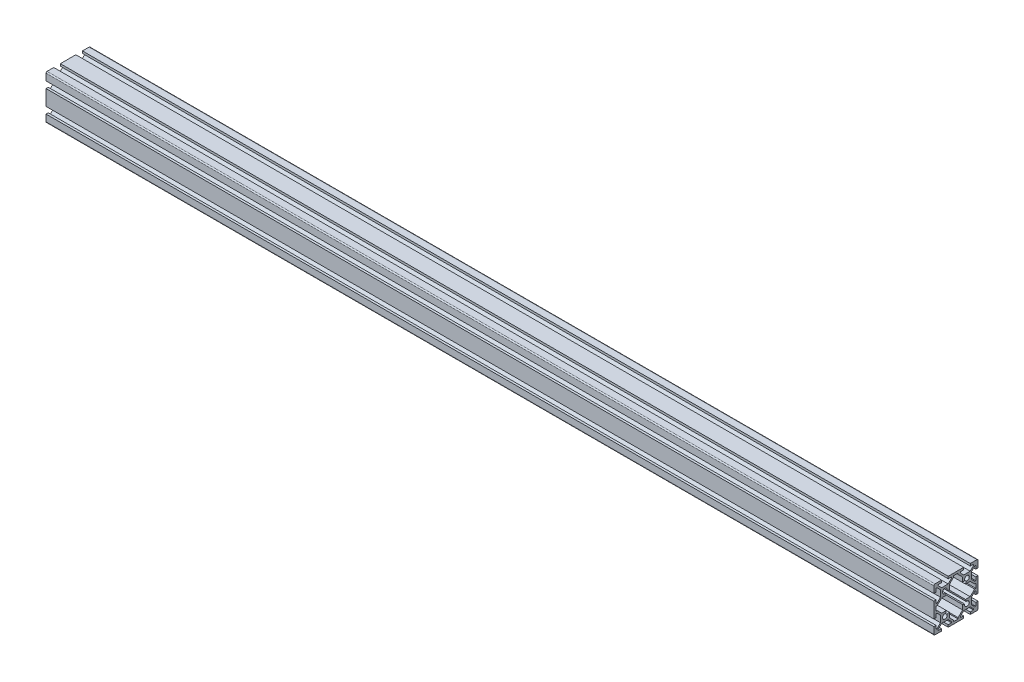
from build123d import *

# Parameters (mm, degrees)
BOSS_EXTRUDE1_DEPTH = 804


with BuildPart() as part:
    # Sketch1 → Boss-Extrude1 (new body)
    with BuildSketch(Plane(origin=(0, 0, 0), x_dir=(0, 0, -1), z_dir=(1, 0, 0))):
        with BuildLine():
            Line((-20, 19), (-20, 13))
            Line((-20, 13), (-18, 13))
            Line((-18, 13), (-18, 16))
            Line((-18, 16), (-17.060660172, 16))
            Line((-17.060660172, 16), (-14, 12.939339828))
            Line((-14, 12.939339828), (-14, 7.060660172))
            Line((-14, 7.060660172), (-17.060660172, 4))
            Line((-17.060660172, 4), (-18, 4))
            Line((-18, 4), (-18, 7))
            Line((-18, 7), (-20, 7))
            Line((-20, 7), (-20, -7))
            Line((-20, -7), (-18, -7))
            Line((-18, -7), (-18, -4))
            Line((-18, -4), (-17.060660172, -4))
            Line((-17.060660172, -4), (-14, -7.060660172))
            Line((-14, -7.060660172), (-14, -12.939339828))
            Line((-14, -12.939339828), (-17.060660172, -16))
            Line((-17.060660172, -16), (-18, -16))
            Line((-18, -16), (-18, -13))
            Line((-18, -13), (-20, -13))
            Line((-20, -13), (-20, -19))
            ThreePointArc((-20, -19), (-19.707106781, -19.707106781), (-19, -20))
            Line((-19, -20), (-13, -20))
            Line((-13, -20), (-13, -18))
            Line((-13, -18), (-16, -18))
            Line((-16, -18), (-16, -17.060660172))
            Line((-16, -17.060660172), (-12.939339828, -14))
            Line((-12.939339828, -14), (-7.060660172, -14))
            Line((-7.060660172, -14), (-4, -17.060660172))
            Line((-4, -17.060660172), (-4, -18))
            Line((-4, -18), (-7, -18))
            Line((-7, -18), (-7, -20))
            Line((-7, -20), (7, -20))
            Line((7, -20), (7, -18))
            Line((7, -18), (4, -18))
            Line((4, -18), (4, -17.060660172))
            Line((4, -17.060660172), (7.060660172, -14))
            Line((7.060660172, -14), (12.939339828, -14))
            Line((12.939339828, -14), (16, -17.060660172))
            Line((16, -17.060660172), (16, -18))
            Line((16, -18), (13, -18))
            Line((13, -18), (13, -20))
            Line((13, -20), (19, -20))
            ThreePointArc((19, -20), (19.707106781, -19.707106781), (20, -19))
            Line((20, -19), (20, -13))
            Line((20, -13), (18, -13))
            Line((18, -13), (18, -16))
            Line((18, -16), (17.060660172, -16))
            Line((17.060660172, -16), (14, -12.939339828))
            Line((14, -12.939339828), (14, -7.060660172))
            Line((14, -7.060660172), (17.060660172, -4))
            Line((17.060660172, -4), (18, -4))
            Line((18, -4), (18, -7))
            Line((18, -7), (20, -7))
            Line((20, -7), (20, 7))
            Line((20, 7), (18, 7))
            Line((18, 7), (18, 4))
            Line((18, 4), (17.060660172, 4))
            Line((17.060660172, 4), (14, 7.060660172))
            Line((14, 7.060660172), (14, 12.939339828))
            Line((14, 12.939339828), (17.060660172, 16))
            Line((17.060660172, 16), (18, 16))
            Line((18, 16), (18, 13))
            Line((18, 13), (20, 13))
            Line((20, 13), (20, 19))
            ThreePointArc((20, 19), (19.707106781, 19.707106781), (19, 20))
            Line((19, 20), (13, 20))
            Line((13, 20), (13, 18))
            Line((13, 18), (16, 18))
            Line((16, 18), (16, 17.060660172))
            Line((16, 17.060660172), (12.939339828, 14))
            Line((12.939339828, 14), (7.060660172, 14))
            Line((7.060660172, 14), (4, 17.060660172))
            Line((4, 17.060660172), (4, 18))
            Line((4, 18), (7, 18))
            Line((7, 18), (7, 20))
            Line((7, 20), (-7, 20))
            Line((-7, 20), (-7, 18))
            Line((-7, 18), (-4, 18))
            Line((-4, 18), (-4, 17.060660172))
            Line((-4, 17.060660172), (-7.060660172, 14))
            Line((-7.060660172, 14), (-12.939339828, 14))
            Line((-12.939339828, 14), (-16, 17.060660172))
            Line((-16, 17.060660172), (-16, 18))
            Line((-16, 18), (-13, 18))
            Line((-13, 18), (-13, 20))
            Line((-13, 20), (-19, 20))
            ThreePointArc((-19, 20), (-19.707106781, 19.707106781), (-20, 19))
        make_face()
        with BuildLine():
            Line((-16.939339828, 2), (-18, 2))
            Line((-18, 2), (-18, -2))
            Line((-18, -2), (-16.939339828, -2))
            Line((-16.939339828, -2), (-12.939339828, -6))
            Line((-12.939339828, -6), (-8.666662697, -6))
            Line((-8.666662697, -6), (-9.335919912, -8.007765667))
            ThreePointArc((-9.335919912, -8.007765667), (-11.48492424, -11.48492424), (-8.007765667, -9.335919912))
            Line((-8.007765667, -9.335919912), (-6, -8.666662697))
            Line((-6, -8.666662697), (-6, -12.939339828))
            Line((-6, -12.939339828), (-2, -16.939339828))
            Line((-2, -16.939339828), (-2, -18))
            Line((-2, -18), (2, -18))
            Line((2, -18), (2, -16.939339828))
            Line((2, -16.939339828), (6, -12.939339828))
            Line((6, -12.939339828), (6, -8.666662697))
            Line((6, -8.666662697), (8.007765667, -9.335919912))
            ThreePointArc((8.007765667, -9.335919912), (11.48492424, -11.48492424), (9.335919912, -8.007765667))
            Line((9.335919912, -8.007765667), (8.666662697, -6))
            Line((8.666662697, -6), (12.939339828, -6))
            Line((12.939339828, -6), (16.939339828, -2))
            Line((16.939339828, -2), (18, -2))
            Line((18, -2), (18, 2))
            Line((18, 2), (16.939339828, 2))
            Line((16.939339828, 2), (12.939339828, 6))
            Line((12.939339828, 6), (8.666662697, 6))
            Line((8.666662697, 6), (9.335919912, 8.007765667))
            ThreePointArc((9.335919912, 8.007765667), (11.48492424, 11.48492424), (8.007765667, 9.335919912))
            Line((8.007765667, 9.335919912), (6, 8.666662697))
            Line((6, 8.666662697), (6, 12.939339828))
            Line((6, 12.939339828), (2, 16.939339828))
            Line((2, 16.939339828), (2, 18))
            Line((2, 18), (-2, 18))
            Line((-2, 18), (-2, 16.939339828))
            Line((-2, 16.939339828), (-6, 12.939339828))
            Line((-6, 12.939339828), (-6, 8.666662697))
            Line((-6, 8.666662697), (-8.007765667, 9.335919912))
            ThreePointArc((-8.007765667, 9.335919912), (-11.48492424, 11.48492424), (-9.335919912, 8.007765667))
            Line((-9.335919912, 8.007765667), (-8.666662697, 6))
            Line((-8.666662697, 6), (-12.939339828, 6))
            Line((-12.939339828, 6), (-16.939339828, 2))
        make_face(mode=Mode.SUBTRACT)
    extrude(amount=BOSS_EXTRUDE1_DEPTH)


solid = part.part
